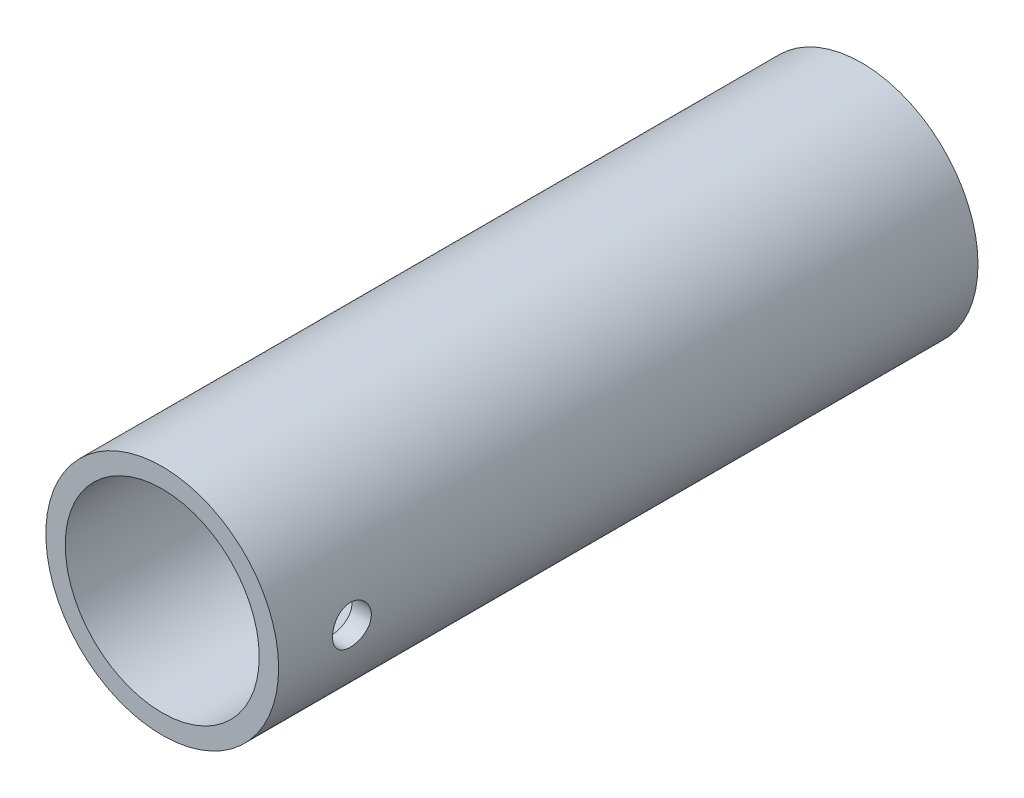
from build123d import *

# Parameters (mm, degrees)
SKETCH1_R           = 9.525
SKETCH1_R_2         = 7.9375
BOSS_EXTRUDE1_DEPTH = 57.239999911
CUT_EXTRUDE1_REACH  = 21.05
SKETCH2_R           = 1.5875
CUT_EXTRUDE2_REACH  = 21.05
SKETCH3_W           = 27.239999911
SKETCH3_H           = 13.5


with BuildPart() as part:
    # Sketch1 → Boss-Extrude1 (new body)
    with BuildSketch(Plane.XY):
        Circle(SKETCH1_R)
        Circle(SKETCH1_R_2, mode=Mode.SUBTRACT)
    extrude(amount=BOSS_EXTRUDE1_DEPTH)

    # Sketch2 → Cut-Extrude1 (cut, up to next)
    with BuildSketch(Plane(origin=(9.525, 0, 0), x_dir=(0, 0, -1), z_dir=(1, 0, 0)), mode=Mode.PRIVATE) as cut_extrude1_sk1:
        with Locations((-51.239999911, 0)):
            Circle(SKETCH2_R)
    cut_extrude1_tool1 = extrude(cut_extrude1_sk1.sketch, amount=-CUT_EXTRUDE1_REACH, mode=Mode.PRIVATE) & part.part
    add(cut_extrude1_tool1.solids().sort_by_distance((9.525, 0, 51.24))[0], mode=Mode.SUBTRACT)

    # Sketch3 → Cut-Extrude2 (cut, up to next)
    with BuildSketch(Plane.ZY.offset(9.525), mode=Mode.PRIVATE) as cut_extrude2_sk1:
        with Locations((26.619999956, -0.25)):
            Rectangle(SKETCH3_W, SKETCH3_H)
    cut_extrude2_tool1 = extrude(cut_extrude2_sk1.sketch, amount=-CUT_EXTRUDE2_REACH, mode=Mode.PRIVATE) & part.part
    add(cut_extrude2_tool1.solids().sort_by_distance((-9.525, -0.25, 26.62))[0], mode=Mode.SUBTRACT)


solid = part.part
